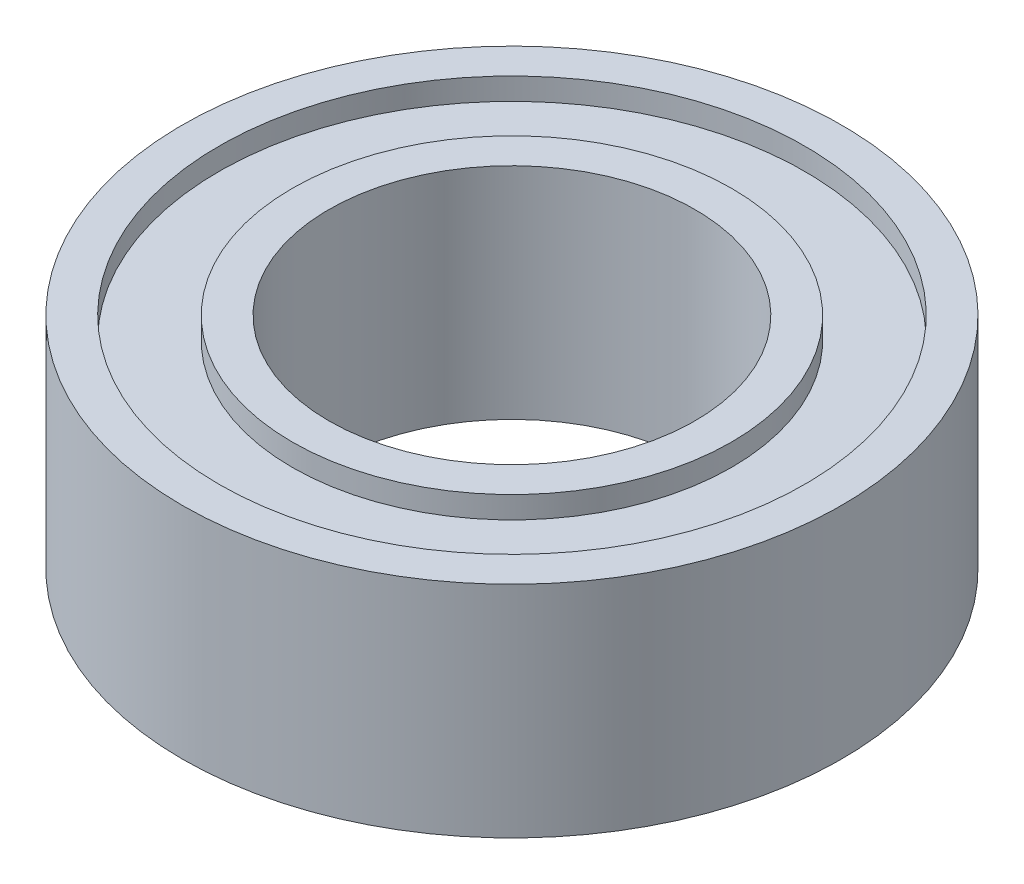
from build123d import *

# Parameters (mm, degrees)
EXTRUDE_1_DEPTH        = 1.5
EXTRUDE_1_DEPTH_BACK   = 1.5
SKETCH_1_R             = 3
SKETCH_1_R_2           = 2.5
EXTRUDE_1_2_DEPTH      = 1.5
EXTRUDE_1_2_DEPTH_BACK = 1.5
SKETCH_1_R_3           = 4.5
SKETCH_1_R_4           = 4
EXTRUDE_2_DEPTH        = 1.2
EXTRUDE_2_DEPTH_BACK   = 1.2
SKETCH_2_R             = 4
SKETCH_2_R_2           = 3


with BuildPart() as part:
    # 草图1 → 凸台-拉伸1 (new, two sides: drawn at the far end of the back side and taken through both)
    with BuildSketch(Plane(origin=(0, 0, 0), x_dir=(1, 0, 0), z_dir=(0, 1, 0)).offset(-EXTRUDE_1_DEPTH_BACK)):
        Circle(SKETCH_1_R)
        Circle(SKETCH_1_R_2, mode=Mode.SUBTRACT)
    extrude(amount=EXTRUDE_1_DEPTH + EXTRUDE_1_DEPTH_BACK)



with BuildPart() as body_2:
    # 草图1 → Extrude 1 2 (new, two sides: drawn at the far end of the back side and taken through both)
    with BuildSketch(Plane(origin=(0, 0, 0), x_dir=(1, 0, 0), z_dir=(0, 1, 0)).offset(-EXTRUDE_1_2_DEPTH_BACK)):
        Circle(SKETCH_1_R_3)
        Circle(SKETCH_1_R_4, mode=Mode.SUBTRACT)
    extrude(amount=EXTRUDE_1_2_DEPTH + EXTRUDE_1_2_DEPTH_BACK)


with BuildPart() as part_1:
    add(part.part)

    add(body_2.part)  # 凸台-拉伸2 merges body 2
    # 草图2 → 凸台-拉伸2 (add, two sides: drawn at the far end of the back side and taken through both)
    with BuildSketch(Plane(origin=(0, 0, 0), x_dir=(1, 0, 0), z_dir=(0, 1, 0)).offset(-EXTRUDE_2_DEPTH_BACK)):
        Circle(SKETCH_2_R)
        Circle(SKETCH_2_R_2, mode=Mode.SUBTRACT)
    extrude(amount=EXTRUDE_2_DEPTH + EXTRUDE_2_DEPTH_BACK)


solid = part_1.part
